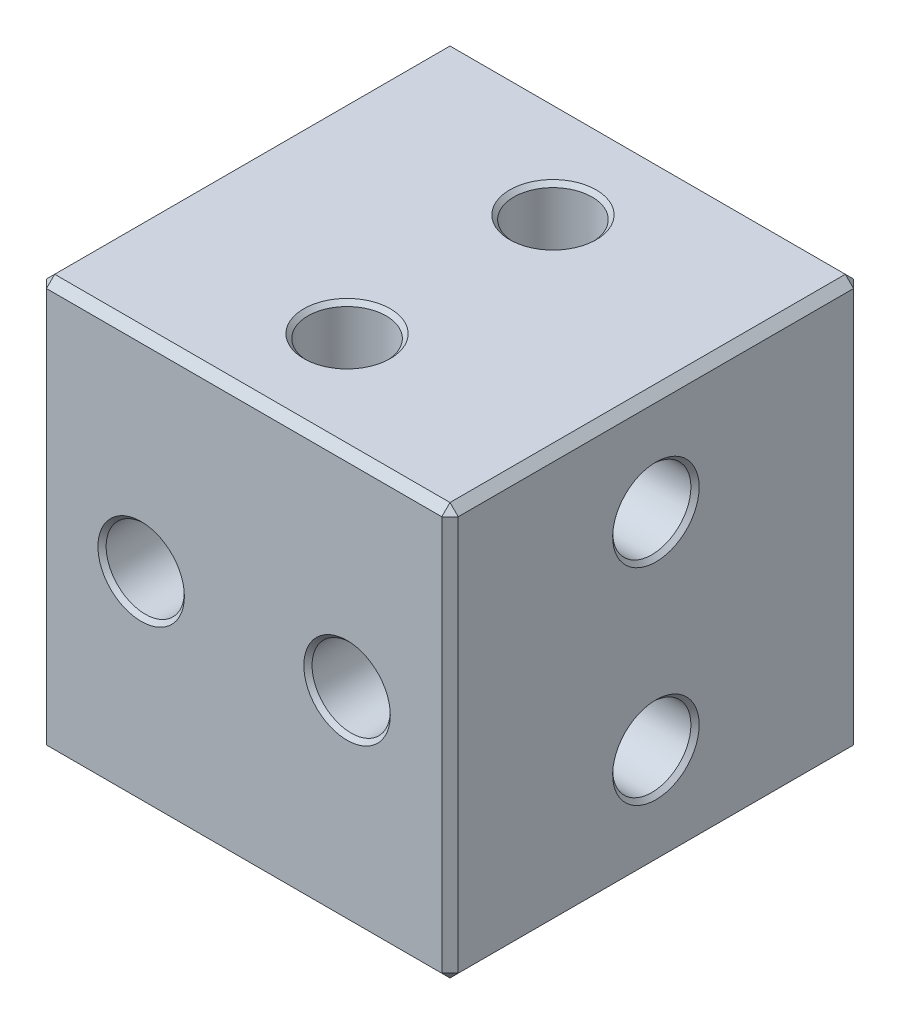
from build123d import *

# Parameters (mm, degrees)
SKETCH1_W           = 10
SKETCH1_H           = 10
BOSS_EXTRUDE1_DEPTH = 10
SKETCH2_R           = 0.95
CUT_EXTRUDE1_DEPTH  = 11
SKETCH3_R           = 0.95
CUT_EXTRUDE2_DEPTH  = 11
SKETCH5_R           = 0.95
CUT_EXTRUDE4_DEPTH  = 11
CHAMFER1_SIZE       = 0.2
CHAMFER2_SIZE       = 0.1


with BuildPart() as part:
    # Sketch1 → Boss-Extrude1 (new body)
    with BuildSketch(Plane.XY):
        Rectangle(SKETCH1_W, SKETCH1_H)
    extrude(amount=BOSS_EXTRUDE1_DEPTH)

    # Sketch2 → Cut-Extrude1 (cut, through all)
    with BuildSketch(Plane.XY.offset(10)):
        with Locations((-2.5, 0)):
            Circle(SKETCH2_R)
        with Locations(Location((2.5, 0, 0), (0, 0, 180))):  # turned: the seam where the file's is
            Circle(SKETCH2_R)
    extrude(amount=-CUT_EXTRUDE1_DEPTH, mode=Mode.SUBTRACT)

    # Sketch3 → Cut-Extrude2 (cut, through all)
    with BuildSketch(Plane(origin=(0, 5, 0), x_dir=(1, 0, 0), z_dir=(0, 1, 0))):
        with Locations(Location((0, -7.5, 0), (0, 0, 90))):  # turned: the seam where the file's is
            Circle(SKETCH3_R)
        with Locations(Location((0, -2.5, 0), (0, 0, 270))):  # turned: the seam where the file's is
            Circle(SKETCH3_R)
    extrude(amount=-CUT_EXTRUDE2_DEPTH, mode=Mode.SUBTRACT)

    # Sketch5 → Cut-Extrude4 (cut, through all)
    with BuildSketch(Plane(origin=(5, 0, 0), x_dir=(0, 0, -1), z_dir=(1, 0, 0))):
        with Locations(Location((-5, 2.5, 0), (0, 0, 90))):  # turned: the seam where the file's is
            Circle(SKETCH5_R)
        with Locations(Location((-5, -2.5, 0), (0, 0, 270))):  # turned: the seam where the file's is
            Circle(SKETCH5_R)
    extrude(amount=-CUT_EXTRUDE4_DEPTH, mode=Mode.SUBTRACT)

    # Chamfer1
    chamfer1_edges = [part.edges().sort_by_distance(p)[0] for p in [
        (5, 0, 10),
        (0, 5, 10),
        (-5, 0, 10),
        (0, 5, 0),
        (5, 0, 0),
        (0, -5, 0),
        (-5, 0, 0),
        (0, -5, 10),
        (-5, 5, 5),
        (5, 5, 5),
        (5, -5, 5),
        (-5, -5, 5),
    ]]
    chamfer(chamfer1_edges, length=CHAMFER1_SIZE)

    # Chamfer2
    chamfer2_edges = [part.edges().sort_by_distance(p)[0] for p in [
        (-3.45, 0, 0),
        (-3.45, 0, 10),
        (3.45, 0, 0),
        (3.45, 0, 10),
        (0, -5, 8.45),
        (0, 5, 8.45),
        (0, -5, 1.55),
        (0, 5, 1.55),
        (-5, 1.55, 5),
        (5, 1.55, 5),
        (-5, -1.55, 5),
        (5, -1.55, 5),
    ]]
    chamfer(chamfer2_edges, length=CHAMFER2_SIZE)


solid = part.part
